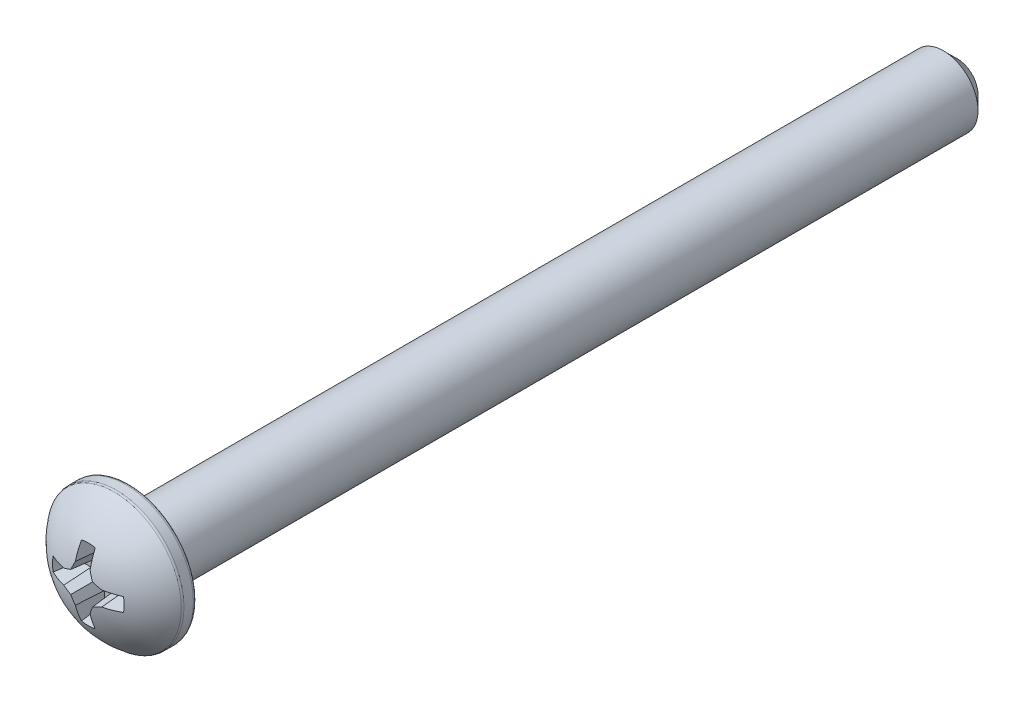
from build123d import *

# Parameters (mm, degrees)
CUT_EXTRUDE1_DEPTH = 1.3563599999999998
DRAFT1_ANGLE       = 15.000000000000034
DRAFT2_ANGLE       = 5.000000000000011


with BuildPart() as part:
    # Sketch2 → Revolve1 (revolve)
    with BuildSketch(Plane(origin=(0, 0, 0), x_dir=(0, 0, -1), z_dir=(1, 0, 0))):
        with BuildLine():
            Line((20.1803, -1.04e-15), (20.1803, 0.9525000000000102))
            Line((20.1803, 0.9525000000000102), (19.5453, 1.5875000000000012))
            Line((19.5453, 1.5875000000000012), (-17.919699999999995, 1.5874999999999961))
            Line((-17.919699999999995, 1.5874999999999961), (-17.919699999999995, 2.9500285714285748))
            ThreePointArc((-17.919699999999995, 2.9500285714285748), (-17.96699388646069, 3.064206113539311), (-18.081171428571423, 3.1115000000000004))
            Line((-18.081171428571423, 3.1115000000000004), (-18.513836667869654, 3.1115000000000004))
            ThreePointArc((-18.513836667869654, 3.1115000000000004), (-18.56365651443409, 3.103622207798032), (-18.60861518645835, 3.0807575072424545))
            ThreePointArc((-18.60861518645835, 3.0807575072424545), (-19.76468125738231, 1.7292527267253457), (-20.1803, -1.04e-15))
            Line((-20.1803, -1.04e-15), (20.1803, -1.04e-15))
        make_face()
    revolve(axis=Axis((0, -1.04e-15, 20.1803), (0, 0, -1)))

    # Sketch3 → Cut-Extrude1 (cut)
    with BuildSketch(Plane.XY.offset(20.1803)):
        with BuildLine():
            Line((0.34999999999999976, 0.8750000000000079), (0.503768939877063, 0.5037689398770607))
            Line((0.503768939877063, 0.5037689398770607), (0.8750000000000099, 0.34999999999999704))
            Line((0.8750000000000099, 0.34999999999999704), (1.7146428199482453, 0.34999999999999704))
            ThreePointArc((1.7146428199482453, 0.34999999999999704), (1.7500000000000198, 3e-17), (1.7146428199482453, -0.34999999999999704))
            Line((1.7146428199482453, -0.34999999999999704), (0.8750000000000099, -0.34999999999999704))
            Line((0.8750000000000099, -0.34999999999999704), (0.503768939877063, -0.5037689398770607))
            Line((0.503768939877063, -0.5037689398770607), (0.34999999999999976, -0.8750000000000079))
            Line((0.34999999999999976, -0.8750000000000079), (0.3499999999999997, -1.7146428199482433))
            ThreePointArc((0.3499999999999997, -1.7146428199482433), (1.1e-16, -1.7500000000000182), (-0.3499999999999997, -1.7146428199482433))
            Line((-0.3499999999999997, -1.7146428199482433), (-0.34999999999999976, -0.8750000000000079))
            Line((-0.34999999999999976, -0.8750000000000079), (-0.503768939877063, -0.5037689398770607))
            Line((-0.503768939877063, -0.5037689398770607), (-0.8750000000000099, -0.34999999999999704))
            Line((-0.8750000000000099, -0.34999999999999704), (-1.7146428199482453, -0.34999999999999704))
            ThreePointArc((-1.7146428199482453, -0.34999999999999704), (-1.7500000000000198, 7.7e-16), (-1.7146428199482453, 0.34999999999999704))
            Line((-1.7146428199482453, 0.34999999999999704), (-0.8750000000000099, 0.34999999999999704))
            Line((-0.8750000000000099, 0.34999999999999704), (-0.503768939877063, 0.5037689398770607))
            Line((-0.503768939877063, 0.5037689398770607), (-0.34999999999999976, 0.8750000000000079))
            Line((-0.34999999999999976, 0.8750000000000079), (-0.3499999999999997, 1.7146428199482433))
            ThreePointArc((-0.3499999999999997, 1.7146428199482433), (1.1e-16, 1.7500000000000182), (0.3499999999999997, 1.7146428199482433))
            Line((0.3499999999999997, 1.7146428199482433), (0.34999999999999976, 0.8750000000000079))
        make_face()
    extrude(amount=-CUT_EXTRUDE1_DEPTH, mode=Mode.SUBTRACT)

    # Draft1
    draft1_faces = [part.faces().sort_by_distance(p)[0] for p in [
        (1.75000000000002, -1.2e-16, 19.288978259234977),
        (1.1e-16, 1.7500000000000182, 19.288978259234973),
        (-1.1e-16, -1.7500000000000182, 19.288978259234973),
        (-1.75000000000002, 1.2e-16, 19.288978259234977),
    ]]
    draft(draft1_faces, Plane.XY.offset(20.1803), DRAFT1_ANGLE)

    # Draft2
    draft2_faces = [part.faces().sort_by_distance(p)[0] for p in [
        (0.34999999999999976, 1.1737349239582924, 19.433218643964523),
        (1.1737349239582944, -0.34999999999999704, 19.433218643964523),
        (0.34999999999999976, -1.1737349239582895, 19.43321864396451),
        (-0.34999999999999976, -1.1737349239582928, 19.433218643964523),
        (-1.1737349235946184, -0.34999999999999704, 19.43321864202573),
        (-1.1737349239582946, 0.34999999999999704, 19.433218643964523),
        (-0.34999999999999976, 1.173734923958288, 19.4332186439645),
        (1.1737349239582153, 0.34999999999999704, 19.433218643964103),
        (0.6881338316552983, 0.4274025012770691, 19.457589851504),
        (0.4274025012770716, 0.6881338316552962, 19.457589851504004),
        (0.6881338316552983, -0.4274025012770691, 19.457589851504004),
        (0.4274025012770716, -0.6881338316552962, 19.457589851504),
        (-0.4274025012770716, -0.6881338316552962, 19.457589851504007),
        (-0.6881338316552983, -0.4274025012770691, 19.457589851504),
        (-0.6881338316552983, 0.4274025012770691, 19.457589851504004),
        (-0.4274025012770716, 0.6881338316552963, 19.457589851504),
    ]]
    draft(draft2_faces, Plane.XY.offset(20.1803), DRAFT2_ANGLE)


solid = part.part
